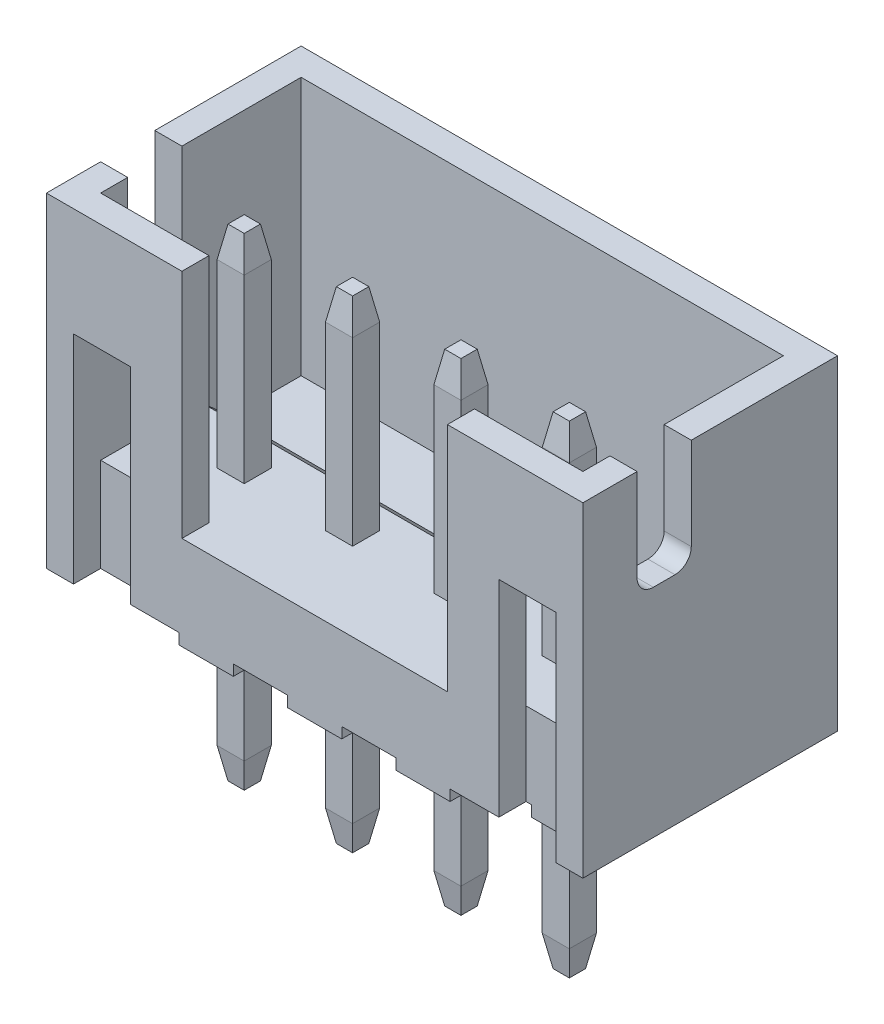
from build123d import *

# Parameters (mm, degrees)
SKETCH_1_W                                 = 4.95
SKETCH_1_H                                 = 4.7
EXTRUDE_1_DEPTH                            = 1.73
EXTRUDE_2_DEPTH                            = 4.27
CUT_EXTRUDE_1_DEPTH                        = 1.5
CUT_EXTRUDE_3_DEPTH                        = 4.45
SKETCH_4_W                                 = 1.05
SKETCH_4_H                                 = 4
SKETCH_4_W_2                               = 2.45
SKETCH_4_H_2                               = 4.27
CUT_EXTRUDE_2_DEPTH                        = 0.5
CUT_EXTRUDE_4_DEPTH                        = 0.5
EXTRUDE_START                              = -5
SKETCH_5_W                                 = 0.5
SKETCH_5_H                                 = 0.5
EXTRUDE_3_DEPTH                            = 8.9
CHAMFER_1_SIZE                             = 0.1
CHAMFER_1_SIZE2                            = 0.567128182
CHAMFER_1_PART_2_SIZE                      = 0.1
CHAMFER_1_PART_2_SIZE2                     = 0.567128182
PATTERN_LINEAR_1_COUNT                     = 4
PATTERN_LINEAR_1_PITCH                     = 2
CHAMFER_1_OF_PATTERN_LINEAR_1_SIZE2        = 0.1
CHAMFER_1_OF_PATTERN_LINEAR_1_SIZE         = 0.567128182
CHAMFER_1_PART_2_OF_PATTERN_LINEAR_1_SIZE2 = 0.1
CHAMFER_1_PART_2_OF_PATTERN_LINEAR_1_SIZE  = 0.567128182


with BuildPart() as part:
    # Эскиз1 → Бобышка-Вытянуть1 (new body)
    with BuildSketch(Plane(origin=(0, 0, 0), x_dir=(1, 0, 0), z_dir=(0, 1, 0))):
        with Locations((-2.475, 0)):
            Rectangle(SKETCH_1_W, SKETCH_1_H)
    extrude_1 = extrude(amount=EXTRUDE_1_DEPTH)

    # Эскиз2 → Бобышка-Вытянуть2 (add)
    with BuildSketch(Plane(origin=(0, 1.73, 0), x_dir=(1, 0, 0), z_dir=(0, 1, 0))):
        Polygon((0, 2.35), (-4.95, 2.35), (-4.95, -2.35), (0, -2.35), (0, -1.85), (-4.45, -1.85), (-4.45, 1.85), (0, 1.85), align=None)
    extrude_2 = extrude(amount=EXTRUDE_2_DEPTH)

    # Эскиз3 → Вырез-Вытянуть1 (cut, through all)
    with BuildSketch(Plane(origin=(-4.45, 0, 0), x_dir=(0, 0, -1), z_dir=(1, 0, 0))):
        with BuildLine():
            Line((-1.35, 6), (-0.35, 6))
            Line((-0.35, 6), (-0.35, 4.3))
            ThreePointArc((-0.35, 4.3), (-0.437867966, 4.087867966), (-0.65, 4))
            Line((-0.65, 4), (-1.05, 4))
            ThreePointArc((-1.05, 4), (-1.262132034, 4.087867966), (-1.35, 4.3))
            Line((-1.35, 4.3), (-1.35, 6))
        make_face()
    cut_extrude_1 = extrude(amount=-CUT_EXTRUDE_1_DEPTH, mode=Mode.SUBTRACT)

    # Эскиз8 → Вырез-Вытянуть3 (cut)
    with BuildSketch(Plane(origin=(0, 0, 0), x_dir=(0, 0, -1), z_dir=(1, 0, 0))):
        Polygon((0, 1.73), (0.55, 1.23), (1.85, 1.23), (1.85, 1.73), align=None)
    cut_extrude_3 = extrude(amount=-CUT_EXTRUDE_3_DEPTH, mode=Mode.SUBTRACT)

    # Эскиз4 → Вырез-Вытянуть2 (cut)
    with BuildSketch(Plane.XY.offset(2.35)):
        with Locations((-3.925, 2)):
            Rectangle(SKETCH_4_W, SKETCH_4_H)
        with Locations((-1.225, 3.865)):
            Rectangle(SKETCH_4_W_2, SKETCH_4_H_2)
    cut_extrude_2 = extrude(amount=-CUT_EXTRUDE_2_DEPTH, mode=Mode.SUBTRACT)

    # Зеркальное отражение1: Бобышка-Вытянуть1, Бобышка-Вытянуть2, Вырез-Вытянуть1, Вырез-Вытянуть3, Вырез-Вытянуть2 across plane
    add(extrude_1.mirror(Plane(origin=(0, 0, 0), x_dir=(0, 0, 1), z_dir=(1, 0, 0))))
    add(extrude_2.mirror(Plane(origin=(0, 0, 0), x_dir=(0, 0, 1), z_dir=(1, 0, 0))))
    add(cut_extrude_1.mirror(Plane(origin=(0, 0, 0), x_dir=(0, 0, 1), z_dir=(1, 0, 0))), mode=Mode.SUBTRACT)
    add(cut_extrude_3.mirror(Plane(origin=(0, 0, 0), x_dir=(0, 0, 1), z_dir=(1, 0, 0))), mode=Mode.SUBTRACT)
    add(cut_extrude_2.mirror(Plane(origin=(0, 0, 0), x_dir=(0, 0, 1), z_dir=(1, 0, 0))), mode=Mode.SUBTRACT)

    # Эскиз9 → Вырез-Вытянуть4 (cut, symmetric)
    with BuildSketch(Plane.ZY.offset(3)):
        Polygon((2.35, 0), (-2.35, 0), (-2.35, 0.5), (-0.05, 0.2), (2.35, 0.2), align=None)
    cut_extrude_4 = extrude(amount=CUT_EXTRUDE_4_DEPTH, both=True, mode=Mode.SUBTRACT)

    # Эскиз5 → Бобышка-Вытянуть3 (add)
    with BuildSketch(Plane(origin=(0, 1.73, 0), x_dir=(1, 0, 0), z_dir=(0, 1, 0)).offset(EXTRUDE_START)):
        with Locations((-3, -0.65)):
            Rectangle(SKETCH_5_W, SKETCH_5_H)
    extrude_3 = extrude(amount=EXTRUDE_3_DEPTH)

    # Фаска1
    chamfer_1_edges = [part.edges().sort_by_distance(p)[0] for p in [
        (-3.25, 5.63, 0.65),
        (-3, 5.63, 0.4),
        (-2.75, 5.63, 0.65),
        (-3, 5.63, 0.9),
    ]]
    chamfer_1_side = [part.faces().sort_by_distance(p)[0] for p in [
        (-3, 5.63, 0.65),
    ]]
    chamfer(chamfer_1_edges, length=CHAMFER_1_SIZE, length2=CHAMFER_1_SIZE2, reference=chamfer_1_side[0])

    # Фаска1 part 2
    chamfer_1_part_2_edges = [part.edges().sort_by_distance(p)[0] for p in [
        (-3.25, -3.27, 0.65),
        (-3, -3.27, 0.4),
        (-2.75, -3.27, 0.65),
        (-3, -3.27, 0.9),
    ]]
    chamfer_1_part_2_side = [part.faces().sort_by_distance(p)[0] for p in [
        (-3, -3.27, 0.65),
    ]]
    chamfer(chamfer_1_part_2_edges, length=CHAMFER_1_PART_2_SIZE, length2=CHAMFER_1_PART_2_SIZE2, reference=chamfer_1_part_2_side[0])

    # Линейный массив1: Вырез-Вытянуть4, Бобышка-Вытянуть3 ×4
    with Locations(*[(i * PATTERN_LINEAR_1_PITCH, 0, 0) for i in range(1, PATTERN_LINEAR_1_COUNT)]):
        add(cut_extrude_4, mode=Mode.SUBTRACT)
        add(extrude_3)

    # Фаска1 of Линейный массив1
    chamfer_1_of_pattern_linear_1_edges = [part.edges().sort_by_distance(p)[0] for p in [
        (-1.25, 5.63, 0.65),
        (-1, 5.63, 0.4),
        (-0.75, 5.63, 0.65),
        (-1, 5.63, 0.9),
        (0.75, 5.63, 0.65),
        (1, 5.63, 0.4),
        (1.25, 5.63, 0.65),
        (1, 5.63, 0.9),
        (2.75, 5.63, 0.65),
        (3, 5.63, 0.4),
        (3.25, 5.63, 0.65),
        (3, 5.63, 0.9),
    ]]
    chamfer(chamfer_1_of_pattern_linear_1_edges, length=CHAMFER_1_OF_PATTERN_LINEAR_1_SIZE, length2=CHAMFER_1_OF_PATTERN_LINEAR_1_SIZE2)

    # Фаска1 part 2 of Линейный массив1
    chamfer_1_part_2_of_pattern_linear_1_edges = [part.edges().sort_by_distance(p)[0] for p in [
        (-1.25, -3.27, 0.65),
        (-1, -3.27, 0.4),
        (-0.75, -3.27, 0.65),
        (-1, -3.27, 0.9),
        (0.75, -3.27, 0.65),
        (1, -3.27, 0.4),
        (1.25, -3.27, 0.65),
        (1, -3.27, 0.9),
        (2.75, -3.27, 0.65),
        (3, -3.27, 0.4),
        (3.25, -3.27, 0.65),
        (3, -3.27, 0.9),
    ]]
    chamfer(chamfer_1_part_2_of_pattern_linear_1_edges, length=CHAMFER_1_PART_2_OF_PATTERN_LINEAR_1_SIZE, length2=CHAMFER_1_PART_2_OF_PATTERN_LINEAR_1_SIZE2)


solid = part.part
